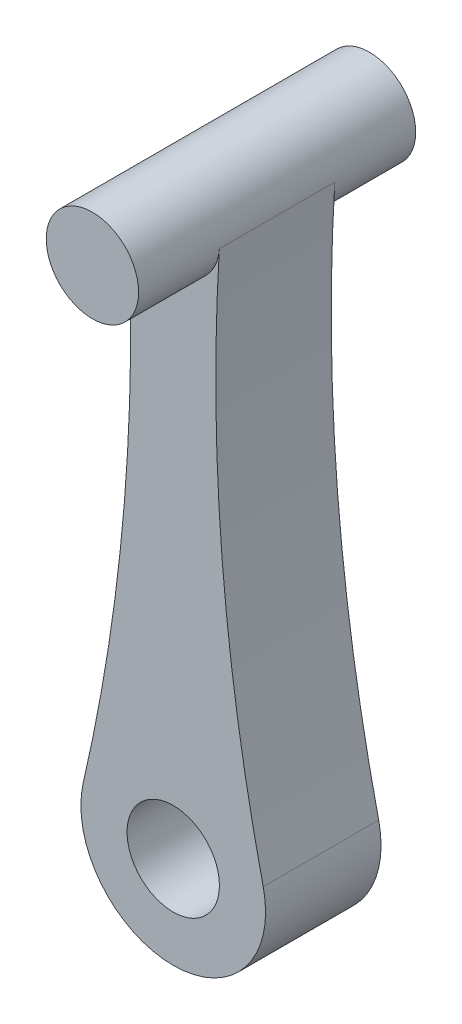
from build123d import *

# Parameters (mm, degrees)
BOSS_EXTRUDE1_DEPTH      = 12.5
BOSS_EXTRUDE1_DEPTH_BACK = 12.5
SKETCH1_R                = 10
SKETCH2_R                = 10
BOSS_EXTRUDE2_DEPTH      = 17.5


with BuildPart() as part:
    # Sketch1 → Boss-Extrude1 (new, two sides: drawn at the far end of the back side and taken through both)
    with BuildSketch(Plane.XY.offset(-BOSS_EXTRUDE1_DEPTH_BACK)):
        with BuildLine():
            ThreePointArc((9.980766544, 59.380081301), (0, 70), (-9.980766544, 59.380081301))
            ThreePointArc((-9.980766544, 59.380081301), (-10.573802909, 1.597827145), (-19.486258491, -55.496031746))
            ThreePointArc((-19.486258491, -55.496031746), (0, -80), (19.486258491, -55.496031746))
            ThreePointArc((19.486258491, -55.496031746), (10.573802909, 1.597827145), (9.980766544, 59.380081301))
        make_face()
        with Locations((0, -60)):
            Circle(SKETCH1_R, mode=Mode.SUBTRACT)
    extrude(amount=BOSS_EXTRUDE1_DEPTH + BOSS_EXTRUDE1_DEPTH_BACK)

    # Sketch2 → Boss-Extrude2 (add)
    with BuildSketch(Plane.XY.offset(12.5)):
        with Locations((0, 60)):
            Circle(SKETCH2_R)
    boss_extrude2 = extrude(amount=BOSS_EXTRUDE2_DEPTH)

    # Mirror1: Boss-Extrude2 across plane
    add(boss_extrude2.mirror(Plane.XY))


solid = part.part
